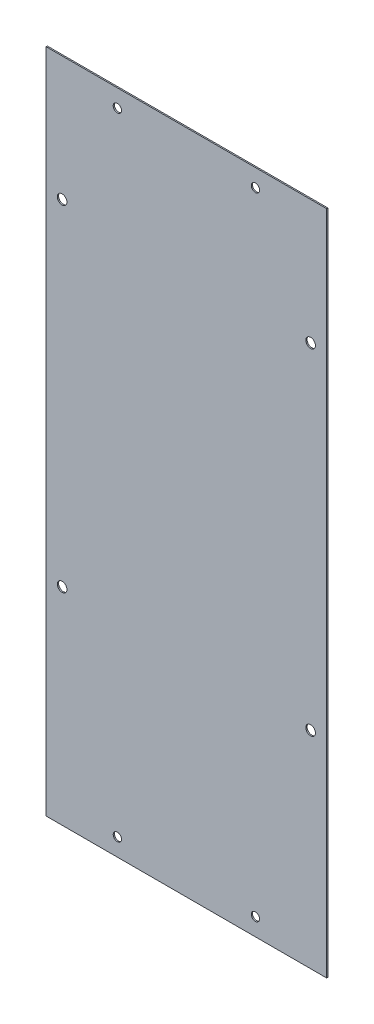
from build123d import *

# Parameters (mm, degrees)
SKETCH_1_W          = 203.2
SKETCH_1_H          = 482.6
EXTRUDE_1_DEPTH     = 0.9
SKETCH_2_R          = 3.5
CUT_EXTRUDE_1_DEPTH = 0.9
SKETCH_3_R          = 3
CUT_EXTRUDE_2_DEPTH = 0.9


with BuildPart() as part:
    # 草图1 → 凸台-拉伸1 (new body)
    with BuildSketch(Plane.XY):
        Rectangle(SKETCH_1_W, SKETCH_1_H)
    extrude(amount=EXTRUDE_1_DEPTH)

    # 草图2 → 切除-拉伸1 (cut)
    with BuildSketch(Plane.XY.offset(0.9)):
        with Locations((-90, 151.3)):
            Circle(SKETCH_2_R)
        with Locations((90, 151.3)):
            Circle(SKETCH_2_R)
        with Locations((90, -91.7)):
            Circle(SKETCH_2_R)
        with Locations((-90, -91.7)):
            Circle(SKETCH_2_R)
    extrude(amount=-CUT_EXTRUDE_1_DEPTH, mode=Mode.SUBTRACT)

    # 草图3 → 切除-拉伸2 (cut)
    with BuildSketch(Plane.XY.offset(0.9)):
        with Locations((-50, 228.6)):
            Circle(SKETCH_3_R)
        with Locations((50, 228.6)):
            Circle(SKETCH_3_R)
        with Locations((50, -228.6)):
            Circle(SKETCH_3_R)
        with Locations((-50, -228.6)):
            Circle(SKETCH_3_R)
    extrude(amount=-CUT_EXTRUDE_2_DEPTH, mode=Mode.SUBTRACT)


solid = part.part
